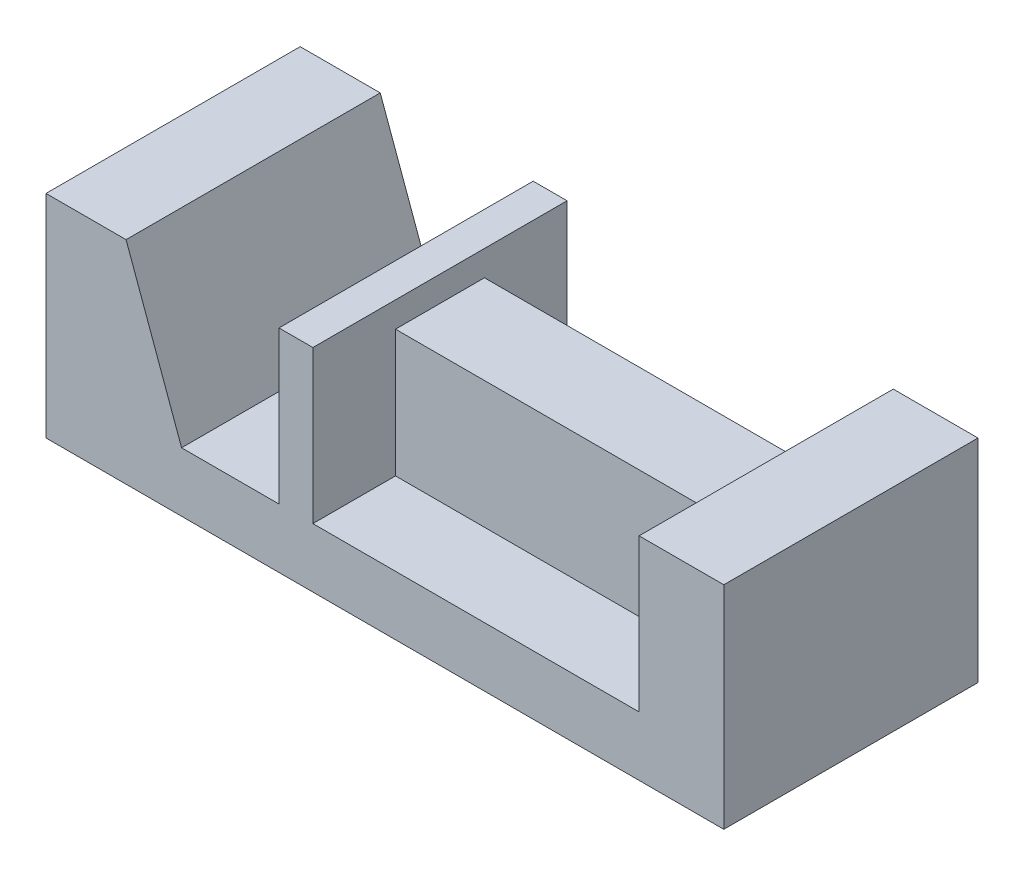
from build123d import *

# Parameters (mm, degrees)
SKETCH2_W           = 160
SKETCH2_H           = 50
BOSS_EXTRUDE1_DEPTH = 60
CUT_EXTRUDE1_DEPTH  = 61
SKETCH4_W           = 77
SKETCH4_H           = 36
CUT_EXTRUDE3_DEPTH  = 61
SKETCH9_W           = 77
SKETCH9_H           = 21
BOSS_EXTRUDE4_DEPTH = 30


with BuildPart() as part:
    # Sketch2 → Boss-Extrude1 (new body)
    with BuildSketch(Plane.XY):
        with Locations((21.725, 25)):
            Rectangle(SKETCH2_W, SKETCH2_H)
    extrude(amount=BOSS_EXTRUDE1_DEPTH)

    # Sketch3 → Cut-Extrude1 (cut, through all)
    with BuildSketch(Plane.XY.offset(60)):
        Polygon((-39.377928434, 50), (-26.275, 14), (-3.275, 14), (-3.275, 50), align=None)
    extrude(amount=-CUT_EXTRUDE1_DEPTH, mode=Mode.SUBTRACT)

    # Sketch4 → Cut-Extrude3 (cut, through all)
    with BuildSketch(Plane.XY.offset(60)):
        with Locations((43.225, 32)):
            Rectangle(SKETCH4_W, SKETCH4_H)
    extrude(amount=-CUT_EXTRUDE3_DEPTH, mode=Mode.SUBTRACT)

    # Sketch9 → Boss-Extrude4 (add)
    with BuildSketch(Plane(origin=(0, 14, 0), x_dir=(1, 0, 0), z_dir=(0, 1, 0))):
        with Locations((43.225, -30)):
            Rectangle(SKETCH9_W, SKETCH9_H)
    extrude(amount=BOSS_EXTRUDE4_DEPTH)


solid = part.part
